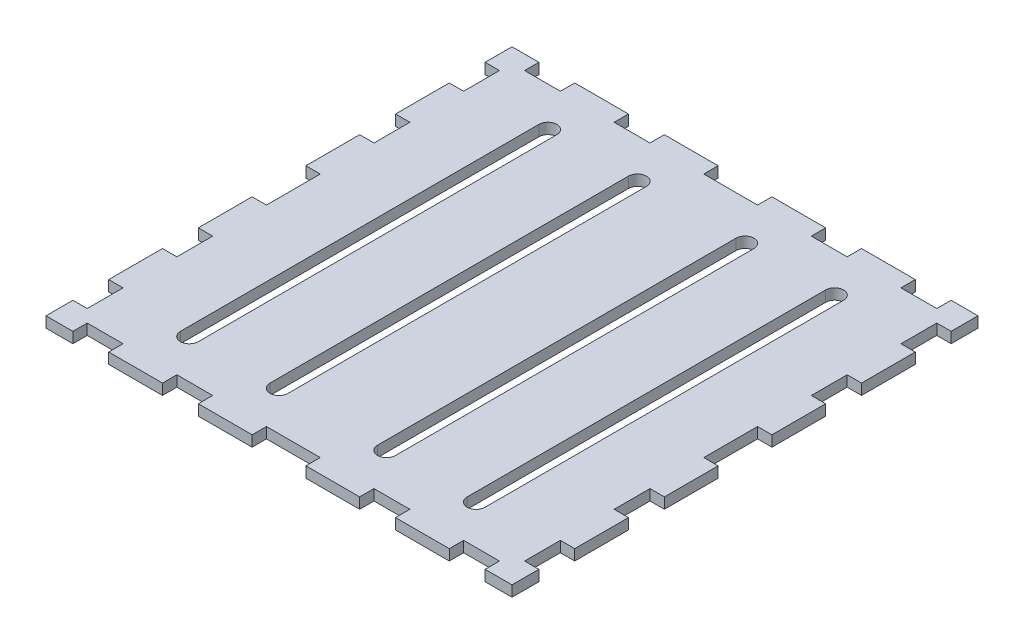
from build123d import *

# Parameters (mm, degrees)
BOSS_EXTRUDE1_DEPTH = 3


with BuildPart() as part:
    # Sketch1 → Boss-Extrude1 (new body)
    with BuildSketch(Plane(origin=(0, 0, 0), x_dir=(1, 0, 0), z_dir=(0, 1, 0))):
        Polygon((-65, -65), (-57.5, -65), (-57.5, -61), (-47.5, -61), (-47.5, -65), (-32.5, -65), (-32.5, -61), (-22.5, -61), (-22.5, -65), (-7.5, -65), (-7.5, -61), (7.5, -61), (7.5, -65), (22.5, -65), (22.5, -61), (32.5, -61), (32.5, -65), (47.5, -65), (47.5, -61), (57.5, -61), (57.5, -65), (65, -65), (65, -57.5), (61, -57.5), (61, -47.5), (65, -47.5), (65, -32.5), (61, -32.5), (61, -22.5), (65, -22.5), (65, -7.5), (61, -7.5), (61, 7.5), (65, 7.5), (65, 22.5), (61, 22.5), (61, 32.5), (65, 32.5), (65, 47.5), (61, 47.5), (61, 57.5), (65, 57.5), (65, 65), (57.5, 65), (57.5, 61), (47.5, 61), (47.5, 65), (32.5, 65), (32.5, 61), (22.5, 61), (22.5, 65), (7.5, 65), (7.5, 61), (-7.5, 61), (-7.5, 65), (-22.5, 65), (-22.5, 61), (-32.5, 61), (-32.5, 65), (-47.5, 65), (-47.5, 61), (-57.5, 61), (-57.5, 65), (-65, 65), (-65, 57.5), (-61, 57.5), (-61, 47.5), (-65, 47.5), (-65, 32.5), (-61, 32.5), (-61, 22.5), (-65, 22.5), (-65, 7.5), (-61, 7.5), (-61, -7.5), (-65, -7.5), (-65, -22.5), (-61, -22.5), (-61, -32.5), (-65, -32.5), (-65, -47.5), (-61, -47.5), (-61, -57.5), (-65, -57.5), align=None)
        with BuildLine():
            Line((-37.5, 50), (-37.5, -50))
            ThreePointArc((-37.5, -50), (-40, -52.5), (-42.5, -50))
            Line((-42.5, -50), (-42.5, 50))
            ThreePointArc((-42.5, 50), (-40, 52.5), (-37.5, 50))
        make_face(mode=Mode.SUBTRACT)
        with BuildLine():
            Line((-12.5, 50), (-12.5, -50))
            ThreePointArc((-12.5, -50), (-15, -52.5), (-17.5, -50))
            Line((-17.5, -50), (-17.5, 50))
            ThreePointArc((-17.5, 50), (-15, 52.5), (-12.5, 50))
        make_face(mode=Mode.SUBTRACT)
        with BuildLine():
            Line((37.5, 50), (37.5, -50))
            ThreePointArc((37.5, -50), (40, -52.5), (42.5, -50))
            Line((42.5, -50), (42.5, 50))
            ThreePointArc((42.5, 50), (40, 52.5), (37.5, 50))
        make_face(mode=Mode.SUBTRACT)
        with BuildLine():
            Line((12.5, 50), (12.5, -50))
            ThreePointArc((12.5, -50), (15, -52.5), (17.5, -50))
            Line((17.5, -50), (17.5, 50))
            ThreePointArc((17.5, 50), (15, 52.5), (12.5, 50))
        make_face(mode=Mode.SUBTRACT)
    extrude(amount=BOSS_EXTRUDE1_DEPTH)


solid = part.part
